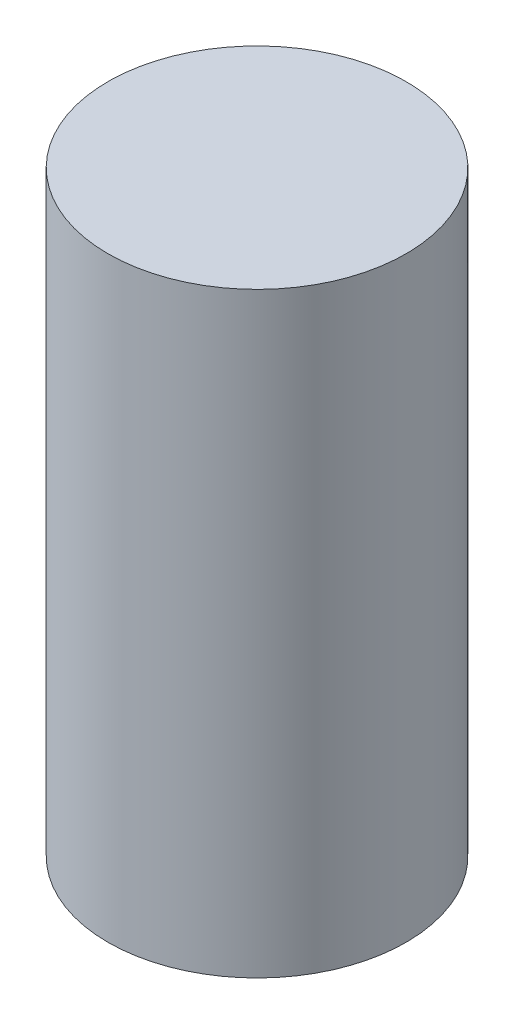
from build123d import *

# Parameters (mm, degrees)
SKETCH1_R      = 10
EXTRUDE1_DEPTH = 40


with BuildPart() as part:
    # Sketch1 → Extrude1 (new body)
    with BuildSketch(Plane(origin=(0, 0, 0), x_dir=(1, 0, 0), z_dir=(0, 1, 0))):
        with Locations(Location((0, 0, 0), (0, 0, 270))):  # turned: the seam where the file's is
            Circle(SKETCH1_R)
    extrude(amount=EXTRUDE1_DEPTH)


solid = part.part
